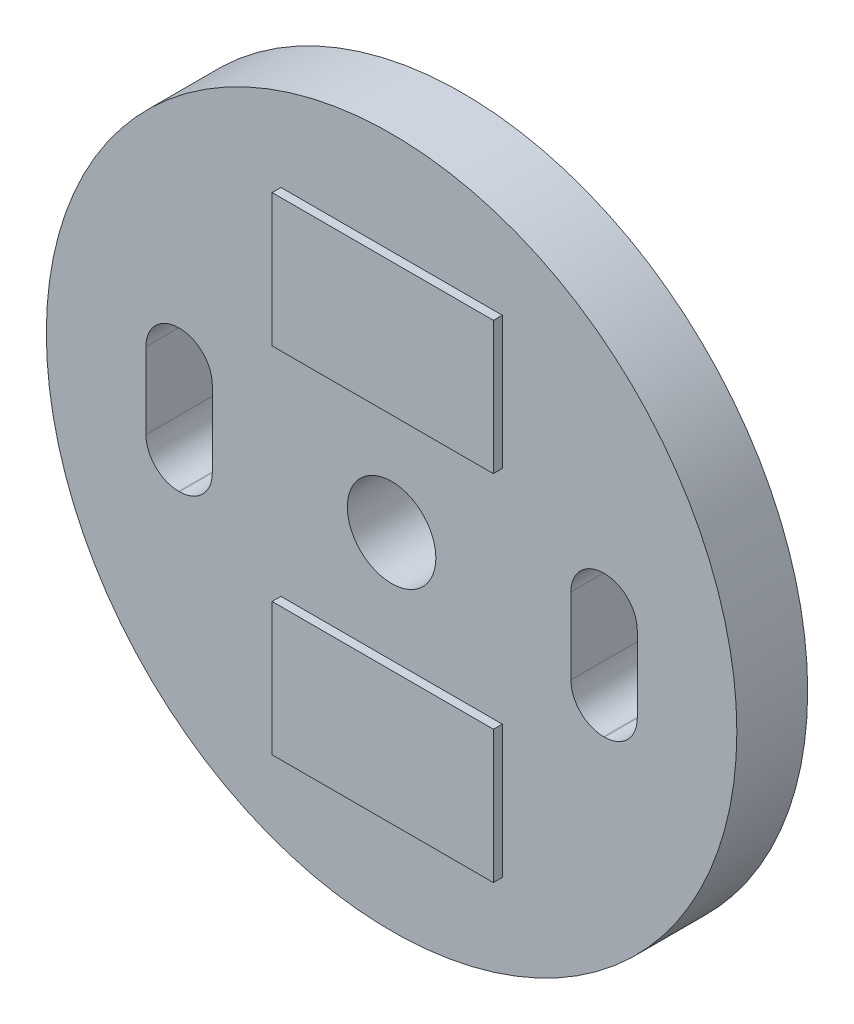
from build123d import *

# Parameters (mm, degrees)
SKETCH_1_R      = 3.9
SKETCH_1_R_2    = 0.5
EXTRUDE_1_DEPTH = 0.8
SKETCH_2_W      = 2.5
SKETCH_2_H      = 1.5
EXTRUDE_2_DEPTH = 0.1


with BuildPart() as part:
    # 草图1 → 凸台-拉伸1 (new body)
    with BuildSketch(Plane.XY):
        Circle(SKETCH_1_R)
        Circle(SKETCH_1_R_2, mode=Mode.SUBTRACT)
        with BuildLine():
            Line((-2.405, 0.8), (-2.395, 0.8))
            ThreePointArc((-2.395, 0.8), (-2.133370491, 0.691629509), (-2.025, 0.43))
            Line((-2.025, 0.43), (-2.025, -0.43))
            ThreePointArc((-2.025, -0.43), (-2.133370491, -0.691629509), (-2.395, -0.8))
            Line((-2.395, -0.8), (-2.405, -0.8))
            ThreePointArc((-2.405, -0.8), (-2.666629509, -0.691629509), (-2.775, -0.43))
            Line((-2.775, -0.43), (-2.775, 0.43))
            ThreePointArc((-2.775, 0.43), (-2.666629509, 0.691629509), (-2.405, 0.8))
        make_face(mode=Mode.SUBTRACT)
        with BuildLine():
            Line((2.395, 0.8), (2.405, 0.8))
            ThreePointArc((2.405, 0.8), (2.666629509, 0.691629509), (2.775, 0.43))
            Line((2.775, 0.43), (2.775, -0.43))
            ThreePointArc((2.775, -0.43), (2.666629509, -0.691629509), (2.405, -0.8))
            Line((2.405, -0.8), (2.395, -0.8))
            ThreePointArc((2.395, -0.8), (2.133370491, -0.691629509), (2.025, -0.43))
            Line((2.025, -0.43), (2.025, 0.43))
            ThreePointArc((2.025, 0.43), (2.133370491, 0.691629509), (2.395, 0.8))
        make_face(mode=Mode.SUBTRACT)
    extrude(amount=EXTRUDE_1_DEPTH)

    # 草图2 → 凸台-拉伸2 (add)
    with BuildSketch(Plane.XY.offset(0.8)):
        with Locations((0, 2)):
            Rectangle(SKETCH_2_W, SKETCH_2_H)
        with Locations((0, -2)):
            Rectangle(SKETCH_2_W, SKETCH_2_H)
    extrude(amount=EXTRUDE_2_DEPTH)


solid = part.part
